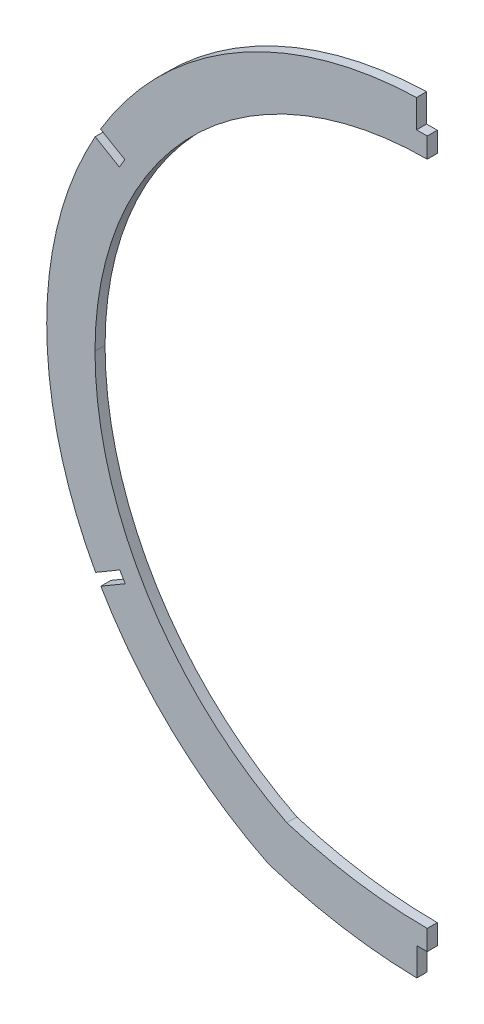
from build123d import *

# Parameters (mm, degrees)
BOSS_EXTRUDE1_DEPTH = 1.5875
SKETCH3_W           = 208.645691316
SKETCH3_H           = 383.026987577
CUT_EXTRUDE1_DEPTH  = 121.20569203
CUT_EXTRUDE2_DEPTH  = 4.175


with BuildPart() as part:
    # Sketch2 → Boss-Extrude1 (new body, symmetric)
    with BuildSketch(Plane.XY):
        with BuildLine():
            ThreePointArc((-120.098895727, 19.05), (0.406748907, 139.2017743), (120.203613722, 18.343301545))
            ThreePointArc((120.203613722, 18.343301545), (101.067699546, -47.629728931), (50.138751442, -93.726))
            ThreePointArc((50.138751442, -93.726), (0.040174098, -101.514794876), (-50.058403246, -93.726))
            ThreePointArc((-50.058403246, -93.726), (-101.163912713, -47.327889321), (-120.098895727, 19.05))
        make_face()
        with BuildLine():
            ThreePointArc((-104.858895727, 19.05), (0.361930242, 123.961840203), (104.963877332, 18.432938489))
            ThreePointArc((104.963877332, 18.432938489), (88.446745877, -39.065849025), (44.40486057, -79.553359885))
            ThreePointArc((44.40486057, -79.553359885), (0.040463589, -86.274794876), (-44.323959374, -79.553531384))
            ThreePointArc((-44.323959374, -79.553531384), (-88.517658334, -38.801393502), (-104.858895727, 19.05))
        make_face(mode=Mode.SUBTRACT)
    extrude(amount=BOSS_EXTRUDE1_DEPTH, both=True)

    # Sketch3 → Cut-Extrude1 (cut, through all)
    with BuildSketch(Plane(origin=(0, 0, 0), x_dir=(0, 0, -1), z_dir=(1, 0, 0))):
        with Locations((4.266053154, 20.866300598)):
            Rectangle(SKETCH3_W, SKETCH3_H)
    extrude(amount=CUT_EXTRUDE1_DEPTH, mode=Mode.SUBTRACT)

    # Sketch4 → Cut-Extrude2 (cut, through all)
    with BuildSketch(Plane.XY.offset(1.5875)):
        with BuildLine():
            Line((-95.442778735, 76.146002016), (-103.1094988, 80.645376586))
            ThreePointArc((-103.1094988, 80.645376586), (-103.96522962, 79.188995674), (-104.80040165, 77.720728574))
            Line((-104.80040165, 77.720728574), (-97.152639859, 73.232480062))
            Line((-97.152639859, 73.232480062), (-95.442778735, 76.146002016))
        make_face()
        with BuildLine():
            Line((-3.3782, 139.153279965), (-3.3782, 130.312293878))
            Line((-3.3782, 130.312293878), (0, 130.312293878))
            Line((0, 130.312293878), (0, 139.202282013))
            ThreePointArc((0, 139.202282013), (-1.689272244, 139.189655502), (-3.3782, 139.153279965))
        make_face()
        with BuildLine():
            Line((-97.044954451, -36.819436689), (-104.679734985, -41.300066711))
            ThreePointArc((-104.679734985, -41.300066711), (-103.859441192, -42.776931517), (-103.019390964, -44.242648808))
            Line((-103.019390964, -44.242648808), (-95.335093375, -39.732958671))
            Line((-95.335093375, -39.732958671), (-97.044954451, -36.819436689))
        make_face()
        with BuildLine():
            Line((-3.302, -92.624794876), (-3.302, -101.48094955))
            ThreePointArc((-3.302, -101.48094955), (-1.651084663, -101.506132106), (0, -101.514794876))
            Line((0, -101.514794876), (0, -92.624794876))
            Line((0, -92.624794876), (-3.302, -92.624794876))
        make_face()
    extrude(amount=-CUT_EXTRUDE2_DEPTH, mode=Mode.SUBTRACT)


solid = part.part
